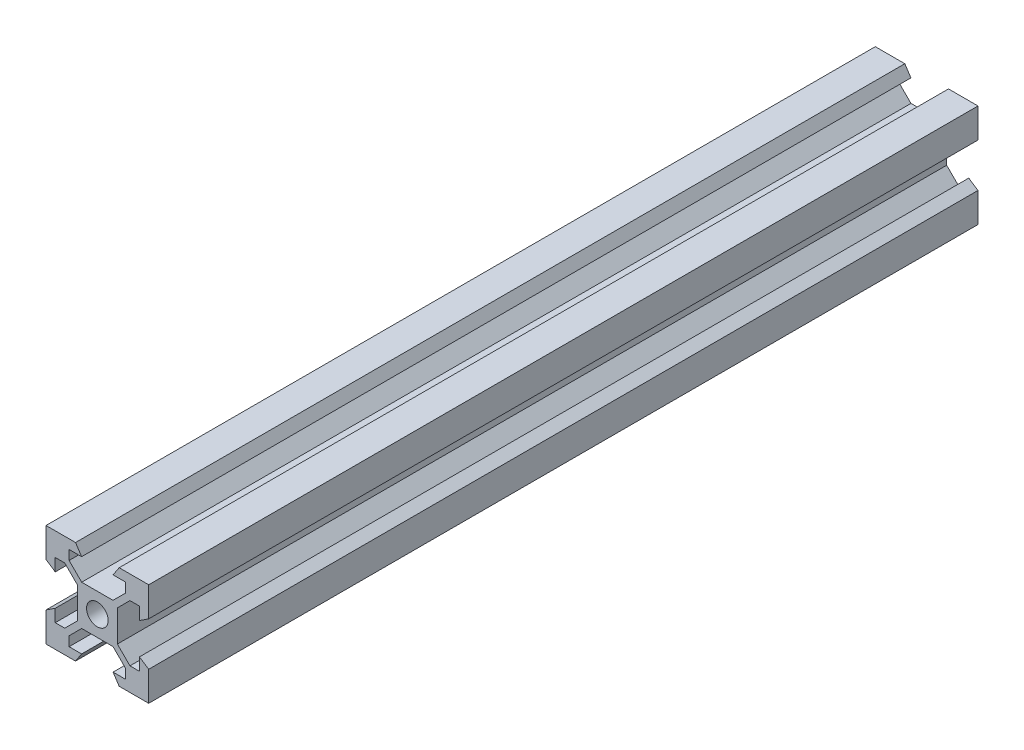
from build123d import *

# Parameters (mm, degrees)
SKETCH1_R           = 2.1
BOSS_EXTRUDE1_DEPTH = 161.5


with BuildPart() as part:
    # Sketch1 → Boss-Extrude1 (new body)
    with BuildSketch(Plane.XY):
        Polygon((-10, 10), (-4.25, 10), (-3.065, 8.2), (-5.5, 8.2), (-5.5, 6.348528137), (-3.051471863, 3.9), (0, 3.9), (3.051471863, 3.9), (5.5, 6.348528137), (5.5, 8.2), (3.065, 8.2), (4.25, 10), (10, 10), (10, 4.25), (8.2, 3.065), (8.2, 5.5), (6.348528137, 5.5), (3.9, 3.051471863), (3.9, 0), (3.9, -3.051471863), (6.348528137, -5.5), (8.2, -5.5), (8.2, -3.065), (10, -4.25), (10, -10), (4.25, -10), (3.065, -8.2), (5.5, -8.2), (5.5, -6.348528137), (3.051471863, -3.9), (0, -3.9), (-3.051471863, -3.9), (-5.5, -6.348528137), (-5.5, -8.2), (-3.065, -8.2), (-4.25, -10), (-10, -10), (-10, -4.25), (-8.2, -3.065), (-8.2, -5.5), (-6.348528137, -5.5), (-3.9, -3.051471863), (-3.9, 0), (-3.9, 3.051471863), (-6.348528137, 5.5), (-8.2, 5.5), (-8.2, 3.065), (-10, 4.25), align=None)
        Circle(SKETCH1_R, mode=Mode.SUBTRACT)
    extrude(amount=BOSS_EXTRUDE1_DEPTH)


solid = part.part
